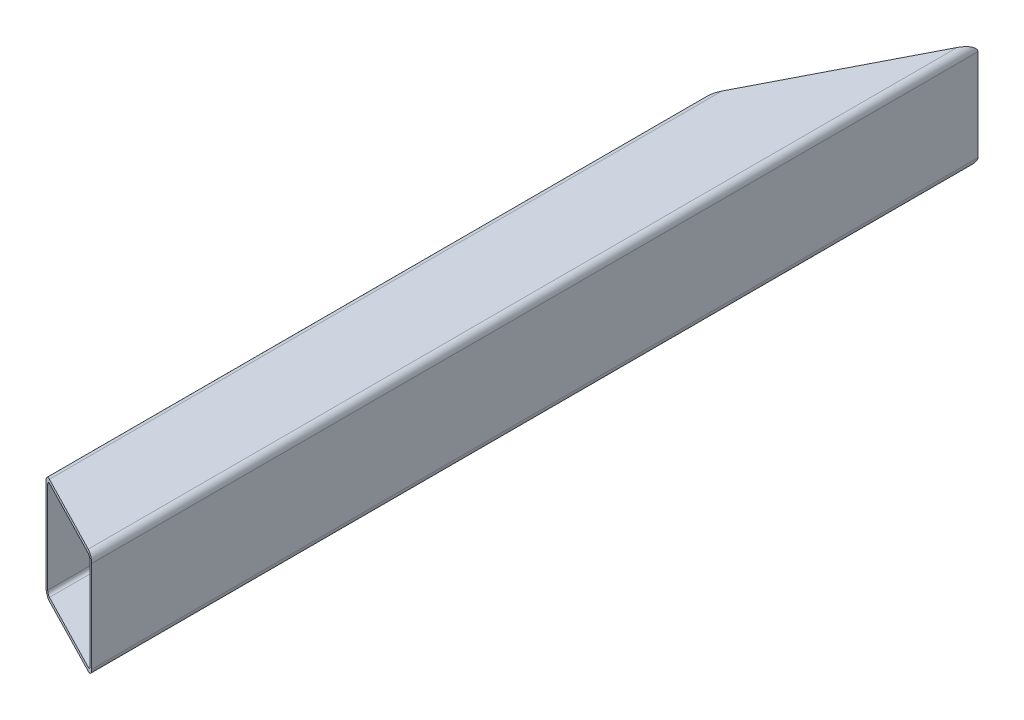
from build123d import *

# Parameters (mm, degrees)
EXTRUDE_1_DEPTH     = 754
CUT_EXTRUDE_1_DEPTH = 60


with BuildPart() as part:
    # Эскиз1 → Вытянуть-Тонкостенный1 (new body)
    with BuildSketch(Plane.XY):
        with BuildLine():
            Line((-40, 39), (-40, -39))
            ThreePointArc((-40, -39), (-38.242640687, -43.242640687), (-34, -45))
            Line((-34, -45), (34, -45))
            ThreePointArc((34, -45), (38.242640687, -43.242640687), (40, -39))
            Line((40, -39), (40, 39))
            ThreePointArc((40, 39), (38.242640687, 43.242640687), (34, 45))
            Line((34, 45), (-34, 45))
            ThreePointArc((-34, 45), (-38.242640687, 43.242640687), (-40, 39))
        make_face()
        with BuildLine():
            Line((-37, 39), (-37, -39))
            ThreePointArc((-37, -39), (-36.121320344, -41.121320344), (-34, -42))
            Line((-34, -42), (34, -42))
            ThreePointArc((34, -42), (36.121320344, -41.121320344), (37, -39))
            Line((37, -39), (37, 39))
            ThreePointArc((37, 39), (36.121320344, 41.121320344), (34, 42))
            Line((34, 42), (-34, 42))
            ThreePointArc((-34, 42), (-36.121320344, 41.121320344), (-37, 39))
        make_face(mode=Mode.SUBTRACT)
    extrude(amount=EXTRUDE_1_DEPTH)

    # Эскиз2 → Вырез-Вытянуть1 (cut, symmetric)
    with BuildSketch(Plane(origin=(0, 0, 0), x_dir=(1, 0, 0), z_dir=(0, 1, 0))):
        Polygon((40, 0), (-40, -155.555555538), (-177.752070978, 72.913369191), (175.578140708, 72.913369191), (175.578140708, -903.068684068), (-185.164592902, -903.068684068), (-40, -712.857142852), (40, -754), align=None)
    extrude(amount=CUT_EXTRUDE_1_DEPTH, both=True, mode=Mode.SUBTRACT)


solid = part.part
